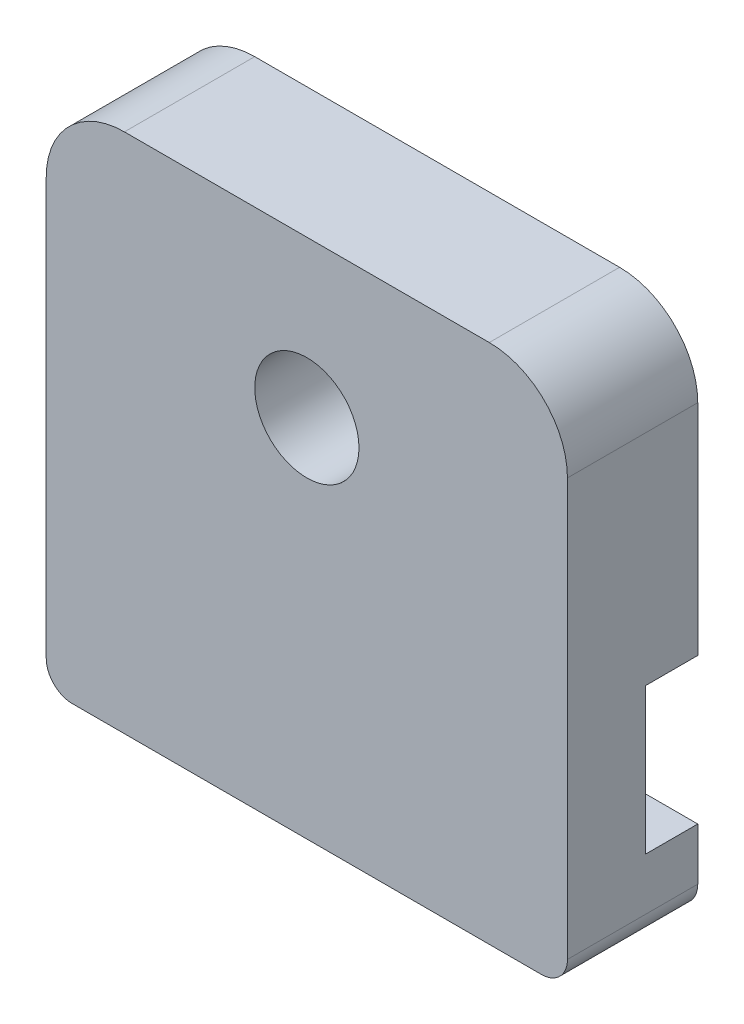
from build123d import *

# Parameters (mm, degrees)
SKETCH1_W           = 20
SKETCH1_H           = 20
BOSS_EXTRUDE1_DEPTH = 5
SKETCH2_R           = 2
CUT_EXTRUDE1_DEPTH  = 6
FILLET1_R           = 3
FILLET2_R           = 1
SKETCH3_W           = 20
SKETCH3_H           = 5.6
CUT_EXTRUDE2_DEPTH  = 2


with BuildPart() as part:
    # Sketch1 → Boss-Extrude1 (new body)
    with BuildSketch(Plane.XY):
        Rectangle(SKETCH1_W, SKETCH1_H)
    extrude(amount=BOSS_EXTRUDE1_DEPTH)

    # Sketch2 → Cut-Extrude1 (cut, through all)
    with BuildSketch(Plane.XY.offset(5)):
        with Locations((0, 4)):
            Circle(SKETCH2_R)
    extrude(amount=-CUT_EXTRUDE1_DEPTH, mode=Mode.SUBTRACT)

    # Fillet1
    fillet1_edges = [part.edges().sort_by_distance(p)[0] for p in [
        (-10, 10, 2.5),
        (10, 10, 2.5),
    ]]
    fillet(fillet1_edges, radius=FILLET1_R)

    # Fillet2
    fillet2_edges = [part.edges().sort_by_distance(p)[0] for p in [
        (10, -10, 2.5),
        (-10, -10, 2.5),
    ]]
    fillet(fillet2_edges, radius=FILLET2_R)

    # Sketch3 → Cut-Extrude2 (cut)
    with BuildSketch(Plane(origin=(0, 0, 0), x_dir=(-1, 0, 0), z_dir=(0, 0, -1))):
        with Locations((0, -4.2)):
            Rectangle(SKETCH3_W, SKETCH3_H)
    extrude(amount=-CUT_EXTRUDE2_DEPTH, mode=Mode.SUBTRACT)


solid = part.part
